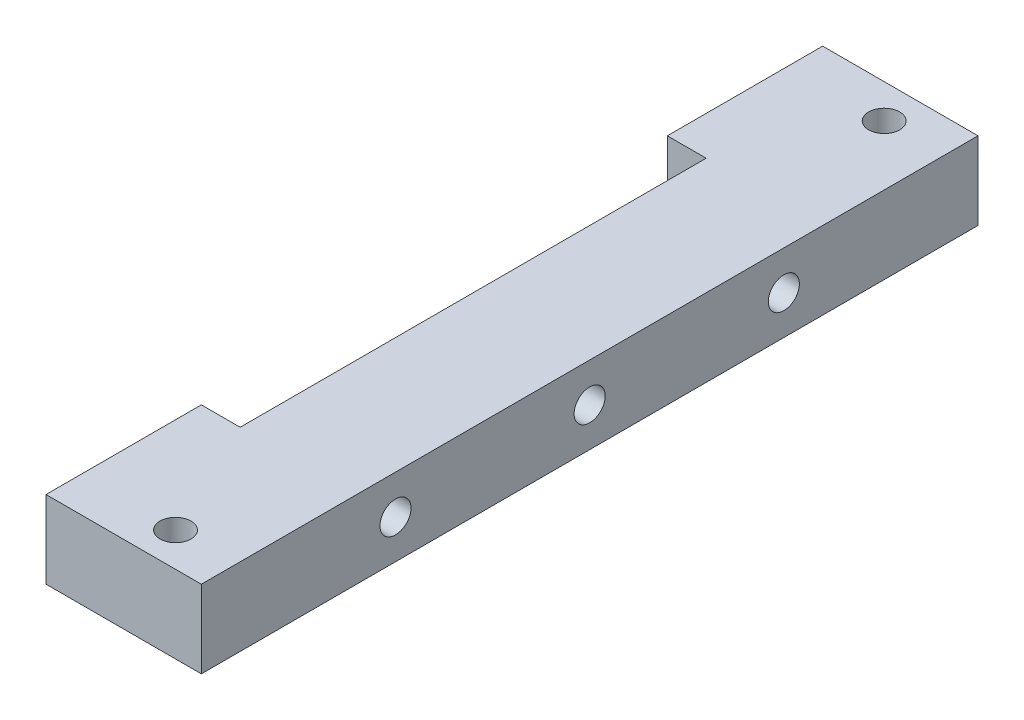
from build123d import *

# Parameters (mm, degrees)
SKETCH1_R           = 2
BOSS_EXTRUDE1_DEPTH = 10
SKETCH2_R           = 2
CUT_EXTRUDE1_DEPTH  = 30
SKETCH3_W           = 147.072515525
SKETCH3_H           = 61.375716436
CUT_EXTRUDE2_DEPTH  = 5


with BuildPart() as part:
    # Sketch1 → Boss-Extrude1 (new body)
    with BuildSketch(Plane(origin=(0, 0, 0), x_dir=(1, 0, 0), z_dir=(0, 1, 0))):
        Polygon((16.050729855, 56.814996593), (-8.949270145, 56.814996593), (-8.949270145, 36.814996593), (1.050729855, 36.814996593), (1.050729855, -23.185003407), (-8.949270145, -23.185003407), (-8.949270145, -43.185003407), (16.050729855, -43.185003407), align=None)
        with Locations((8.348885954, 52.436102934)):
            Circle(SKETCH1_R, mode=Mode.SUBTRACT)
        with Locations((8.348885954, -38.806109747)):
            Circle(SKETCH1_R, mode=Mode.SUBTRACT)
    extrude(amount=BOSS_EXTRUDE1_DEPTH)

    # Sketch2 → Cut-Extrude1 (cut)
    with BuildSketch(Plane.ZY.offset(-1.050729855)):
        with Locations((-31.814996593, 5)):
            Circle(SKETCH2_R)
        with Locations((18.185003407, 5)):
            Circle(SKETCH2_R)
        with Locations((-6.814996593, 5)):
            Circle(SKETCH2_R)
    extrude(amount=-CUT_EXTRUDE1_DEPTH, mode=Mode.SUBTRACT)

    # Sketch3 → Cut-Extrude2 (cut)
    with BuildSketch(Plane.ZY.offset(8.949270145)):
        with Locations((-8.47035824, 7.801381248)):
            Rectangle(SKETCH3_W, SKETCH3_H)
    extrude(amount=-CUT_EXTRUDE2_DEPTH, mode=Mode.SUBTRACT)


solid = part.part
